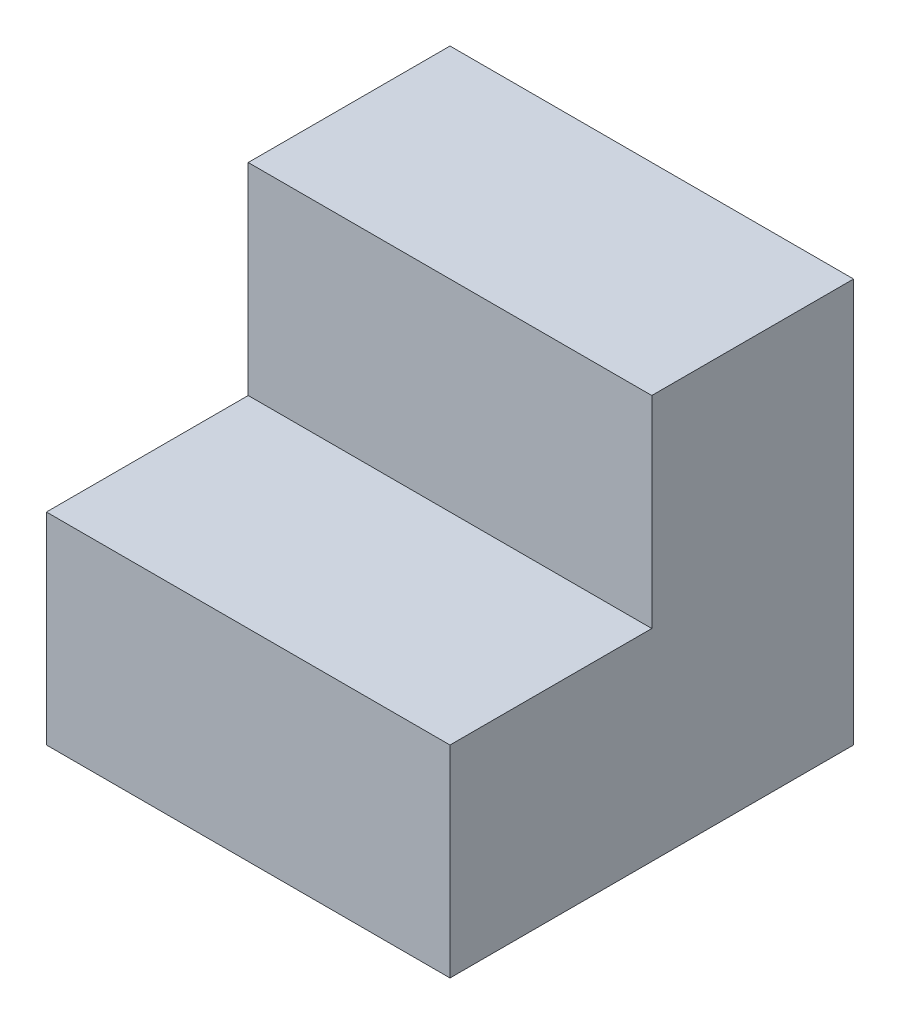
from build123d import *

# Parameters (mm, degrees)
BOSS_EXTRUDE1_DEPTH = 15


with BuildPart() as part:
    # Sketch1 → Boss-Extrude1 (new body, symmetric)
    with BuildSketch(Plane(origin=(0, 0, 0), x_dir=(0, 0, -1), z_dir=(1, 0, 0))):
        Polygon((-30, 15), (-15, 15), (-15, 30), (0, 30), (0, 0), (-30, 0), align=None)
    extrude(amount=BOSS_EXTRUDE1_DEPTH, both=True)


solid = part.part
